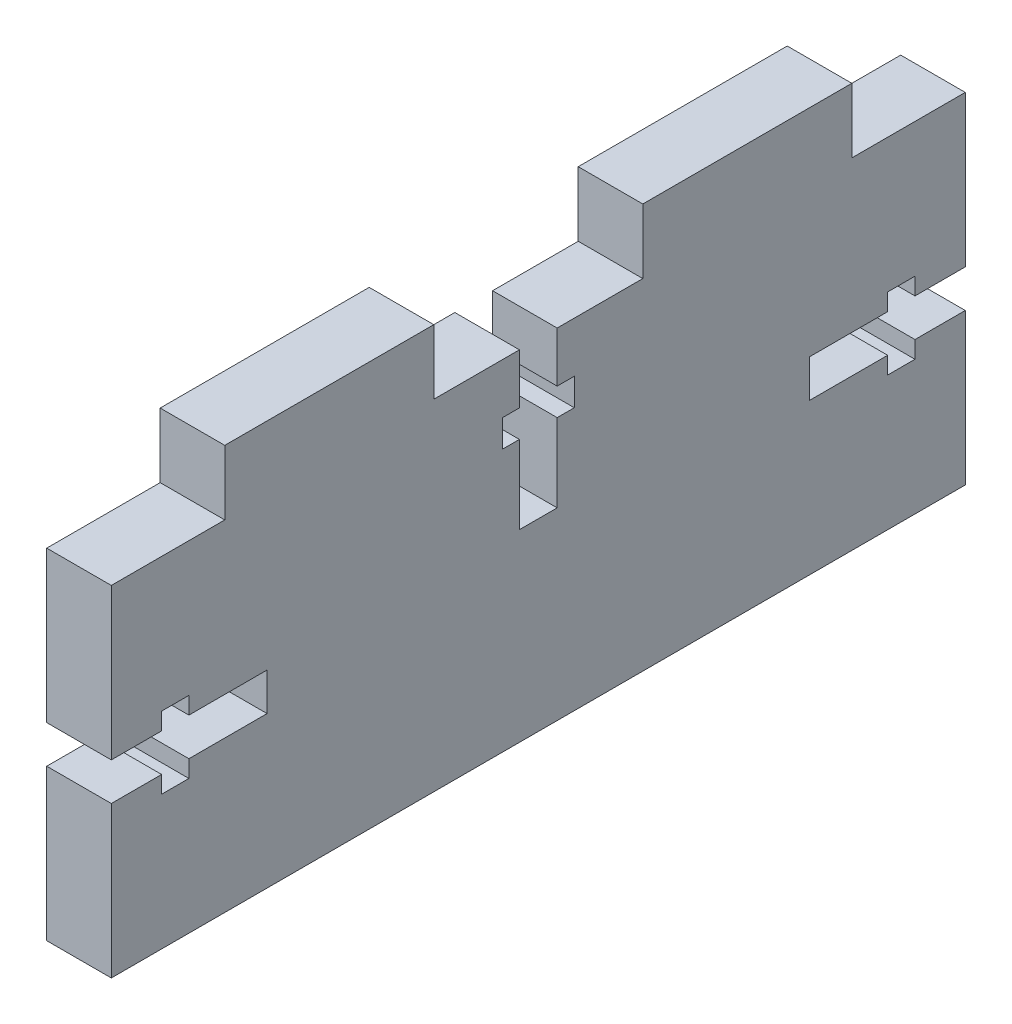
from build123d import *

# Parameters (mm, degrees)
SKETCH2_W               = 67.818
SKETCH2_H               = 27
BOSS_EXTRUDE1_DEPTH     = 5.13
SKETCH3_W               = 5.13
SKETCH3_H               = 16.6
BOSS_EXTRUDE2_DEPTH     = 5.13
CUT_EXTRUDE3_DEPTH      = 61.147579992
CUT_EXTRUDE3_DEPTH_BACK = 61.147579992
T_SLOT_DEPTH            = 61.147579992
T_SLOT_DEPTH_BACK       = 61.147579992
CUT_EXTRUDE6_DEPTH      = 61.147579992
CUT_EXTRUDE6_DEPTH_BACK = 61.147579992


with BuildPart() as part:
    # Sketch2 → Boss-Extrude1 (new body)
    with BuildSketch(Plane(origin=(0, 0, 0), x_dir=(0, 0, -1), z_dir=(1, 0, 0))):
        with Locations((-18.586734769, 10.276959542)):
            Rectangle(SKETCH2_W, SKETCH2_H)
    extrude(amount=BOSS_EXTRUDE1_DEPTH)

    # Sketch3 → Boss-Extrude2 (add)
    with BuildSketch(Plane(origin=(0, 23.776959542, 0), x_dir=(1, 0, 0), z_dir=(0, 1, 0))):
        with Locations((2.565, -1.986734769)):
            Rectangle(SKETCH3_W, SKETCH3_H)
        with Locations((2.565, -35.186734769)):
            Rectangle(SKETCH3_W, SKETCH3_H)
    extrude(amount=BOSS_EXTRUDE2_DEPTH)

    # Sketch6 → Cut-Extrude3 (cut, two sides: drawn at the far end of the back side and taken through both)
    with BuildSketch(Plane(origin=(5.13, 0, 0), x_dir=(0, 0, -1), z_dir=(1, 0, 0)).offset(-CUT_EXTRUDE3_DEPTH_BACK)):
        Polygon((-20.085230125, 122.831802954), (-20.085230125, 23.776960132), (-20.085230125, 19.781960132), (-21.444233122, 19.781960399), (-21.444233548, 17.614960399), (-20.085233548, 17.614960132), (-20.085234769, 11.407960132), (-17.088234769, 11.407959542), (-17.088233548, 17.614959542), (-15.729233548, 17.614959275), (-15.729233122, 19.781959275), (-17.088231927, 19.781959542), (-17.088231927, 23.776959542), (-17.088231927, 122.831802365), (-17.088192956, 320.94148801), (-20.085191154, 320.9414886), align=None)
    extrude(amount=CUT_EXTRUDE3_DEPTH + CUT_EXTRUDE3_DEPTH_BACK, mode=Mode.SUBTRACT)

    # Sketch4 → t-slot (cut, two sides: drawn at the far end of the back side and taken through both)
    with BuildSketch(Plane(origin=(5.13, 0, 0), x_dir=(0, 0, -1), z_dir=(1, 0, 0)).offset(-T_SLOT_DEPTH_BACK)):
        Polygon((-203.979833818, 8.778464186), (-52.495735359, 8.778464186), (-48.500735359, 8.778464186), (-48.500735626, 7.419461189), (-46.333735626, 7.419460763), (-46.333735359, 8.778460763), (-40.126735359, 8.778459542), (-40.126734769, 11.775459542), (-46.333734769, 11.775460763), (-46.333734502, 13.134460763), (-48.500734502, 13.134461189), (-48.500734769, 11.775462385), (-52.495734769, 11.775462385), (-203.979833229, 11.775462385), (-506.948030149, 11.775521982), (-506.948030738, 8.778523784), align=None)
    extrude(amount=T_SLOT_DEPTH + T_SLOT_DEPTH_BACK, mode=Mode.SUBTRACT)

    # Sketch7 → Cut-Extrude6 (cut, two sides: drawn at the far end of the back side and taken through both)
    with BuildSketch(Plane(origin=(5.13, 0, 0), x_dir=(0, 0, -1), z_dir=(1, 0, 0)).offset(-CUT_EXTRUDE6_DEPTH_BACK)):
        Polygon((166.806365691, 11.775454898), (15.322265231, 11.775454898), (11.327265231, 11.775454898), (11.327265498, 13.134457895), (9.160265498, 13.134458321), (9.160265231, 11.775458321), (2.953265231, 11.775459542), (2.953264641, 8.778459542), (9.160264641, 8.778458321), (9.160264374, 7.419458321), (11.327264374, 7.419457895), (11.327264641, 8.7784567), (15.322264641, 8.7784567), (166.806365101, 8.7784567), (469.77456602, 8.778397102), (469.77456661, 11.7753953), align=None)
    extrude(amount=CUT_EXTRUDE6_DEPTH + CUT_EXTRUDE6_DEPTH_BACK, mode=Mode.SUBTRACT)


solid = part.part
